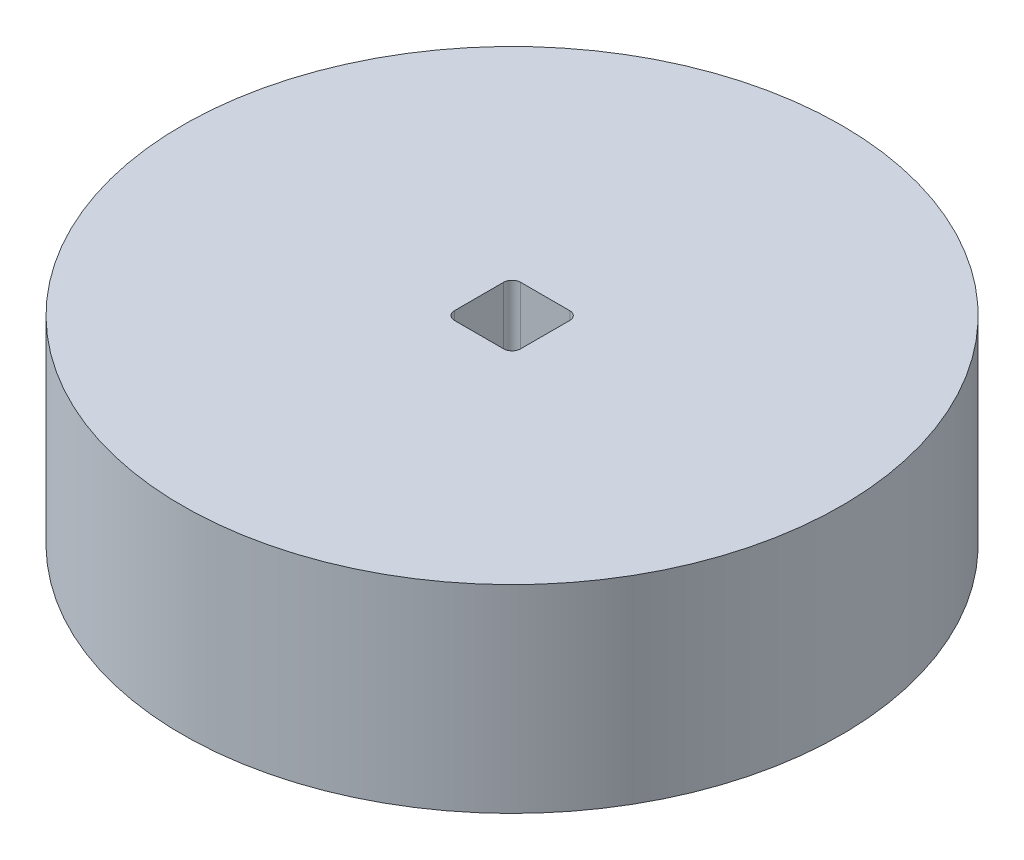
from build123d import *

# Parameters (mm, degrees)
SKETCH_1_R      = 34.925
EXTRUDE_1_DEPTH = 21


with BuildPart() as part:
    # 草图1 → 凸台-拉伸1 (new body)
    with BuildSketch(Plane(origin=(0, 0, 0), x_dir=(1, 0, 0), z_dir=(0, 1, 0))):
        with Locations(Location((0, 0, 0), (0, 0, 90))):
            Circle(SKETCH_1_R)
        with BuildLine():
            Line((-2.601341773, 3.505973477), (2.608658475, 3.505973477))
            ThreePointArc((2.608658475, 3.505973477), (3.245054563, 3.242369587), (3.508658453, 2.605973499))
            Line((3.508658453, 2.605973499), (3.508658453, -2.604026749))
            ThreePointArc((3.508658453, -2.604026749), (3.245054563, -3.240422836), (2.608658475, -3.504026727))
            Line((2.608658475, -3.504026727), (-2.601341773, -3.504026727))
            ThreePointArc((-2.601341773, -3.504026727), (-3.23773786, -3.240422836), (-3.501341751, -2.604026749))
            Line((-3.501341751, -2.604026749), (-3.501341751, 2.605973499))
            ThreePointArc((-3.501341751, 2.605973499), (-3.23773786, 3.242369587), (-2.601341773, 3.505973477))
        make_face(mode=Mode.SUBTRACT)
    extrude(amount=EXTRUDE_1_DEPTH)


solid = part.part
